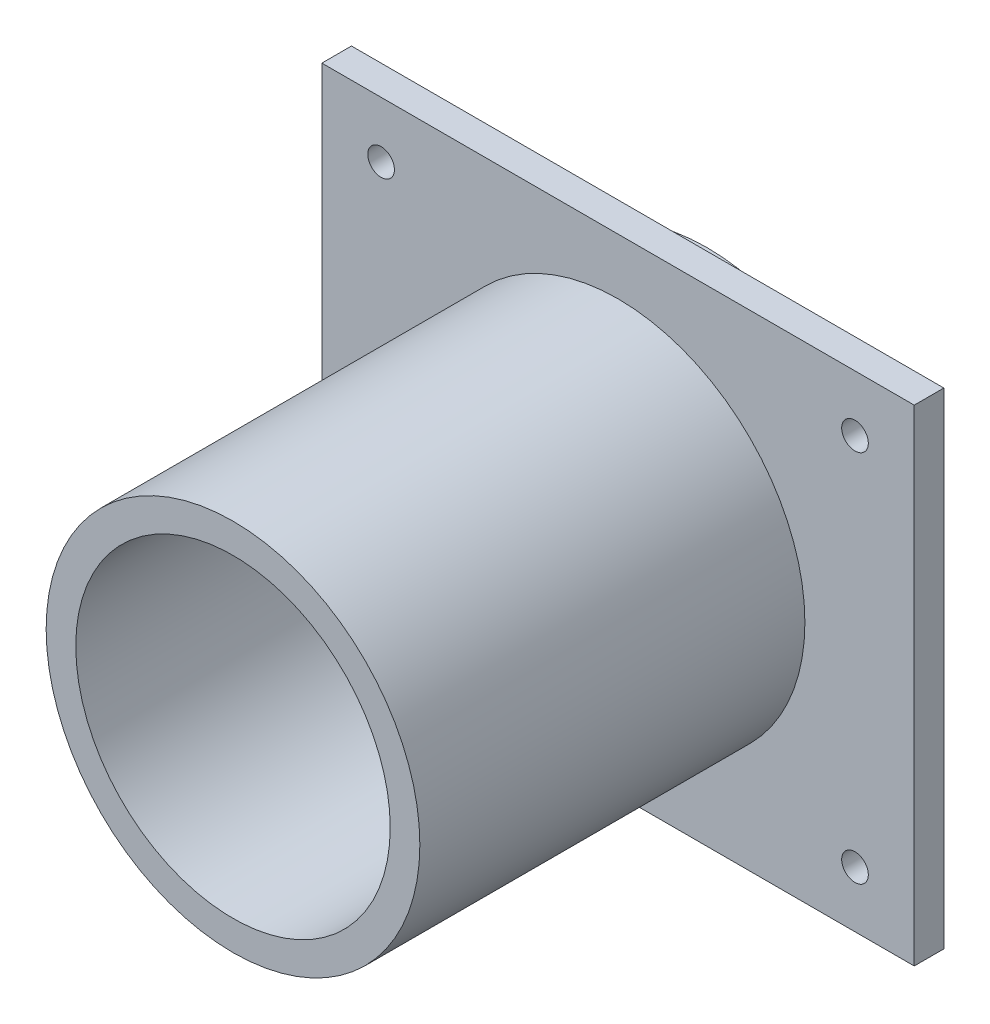
from build123d import *

# Parameters (mm, degrees)
SKETCH1_R                = 31.543
SKETCH1_R_2              = 26.543
BOSS_EXTRUDE1_DEPTH      = 10
SKETCH2_W                = 100
SKETCH2_H                = 82
BOSS_EXTRUDE2_DEPTH      = 5
M4_CLEARANCE_HOLE2_D     = 4.5
M4_CLEARANCE_HOLE2_DEPTH = 5
SKETCH8_R                = 31.543
SKETCH8_R_2              = 26.543
BOSS_EXTRUDE3_DEPTH      = 65


with BuildPart() as part:
    # Sketch1 → Boss-Extrude1 (new body)
    with BuildSketch(Plane.XY):
        Circle(SKETCH1_R)
        Circle(SKETCH1_R_2, mode=Mode.SUBTRACT)
    extrude(amount=-BOSS_EXTRUDE1_DEPTH)

    # Sketch2 → Boss-Extrude2 (add)
    with BuildSketch(Plane.XY):
        Rectangle(SKETCH2_W, SKETCH2_H)
    extrude(amount=BOSS_EXTRUDE2_DEPTH)

    # M4 Clearance Hole2
    with Locations(Plane(origin=(0, 0, 0), x_dir=(-1, 0, 0), z_dir=(0, 0, -1))):
        with Locations((-40, 31.543), (40, 31.543), (40, -31.543), (-40, -31.543)):
            Hole(M4_CLEARANCE_HOLE2_D / 2, depth=M4_CLEARANCE_HOLE2_DEPTH)

    # Sketch8 → Boss-Extrude3 (add)
    with BuildSketch(Plane.XY.offset(5)):
        Circle(SKETCH8_R)
        Circle(SKETCH8_R_2, mode=Mode.SUBTRACT)
    extrude(amount=BOSS_EXTRUDE3_DEPTH)


solid = part.part
